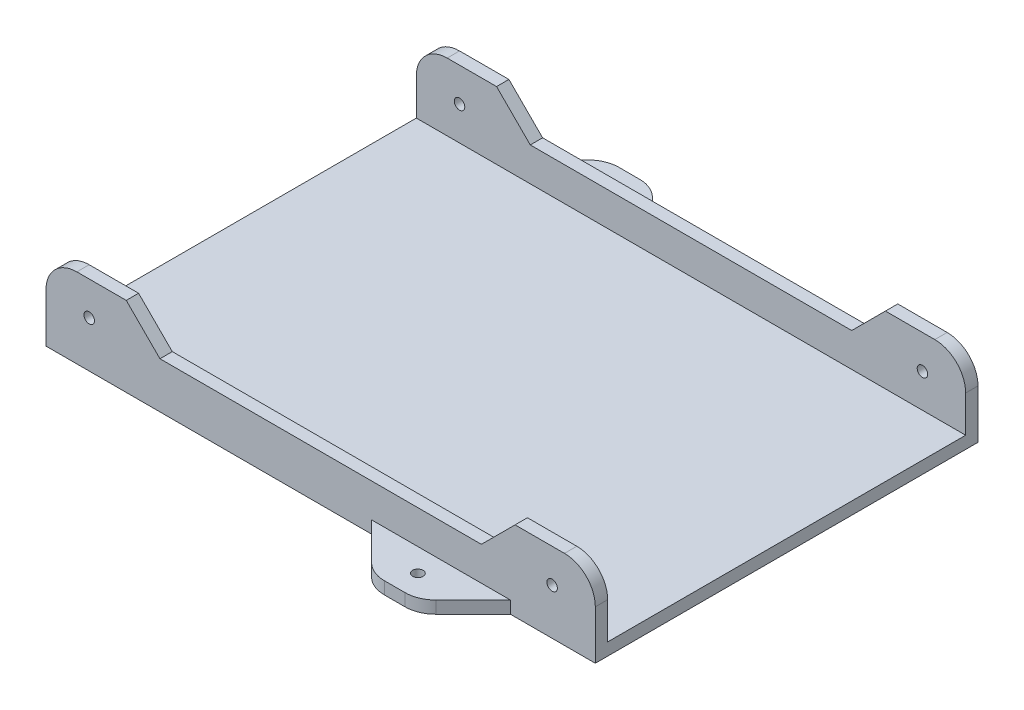
from build123d import *

# Parameters (mm, degrees)
SKETCH1_W               = 178
SKETCH1_H               = 25.844
SKETCH1_R               = 1.7
BOSS_EXTRUDE1_DEPTH     = 4
SKETCH1_3_W             = 178
SKETCH1_3_H             = 4
BOSS_EXTRUDE2_DEPTH     = 116
BOSS_EXTRUDE3_START     = 4
SKETCH2_W               = 178
SKETCH2_H               = 25.844
SKETCH2_R               = 1.7
BOSS_EXTRUDE3_DEPTH     = 4
FILLET1_R               = 10
SKETCH3_R               = 1.7
BOSS_EXTRUDE4_DEPTH     = 4
FILLET2_R               = 10
CUT_EXTRUDE1_DEPTH      = 227.896805478
CUT_EXTRUDE1_DEPTH_BACK = 227.896805478
SKETCH4_R               = 1.7


with BuildPart() as part:
    # Sketch1 → Boss-Extrude1 (new body)
    with BuildSketch(Plane.XY):
        with Locations((89, 8.922)):
            Rectangle(SKETCH1_W, SKETCH1_H)
        with Locations((14, 10.922)):
            Circle(SKETCH1_R, mode=Mode.SUBTRACT)
        with Locations((164, 10.922)):
            Circle(SKETCH1_R, mode=Mode.SUBTRACT)
    extrude(amount=BOSS_EXTRUDE1_DEPTH)

    # Sketch1_3 → Boss-Extrude2 (add)
    with BuildSketch(Plane.XY):
        with Locations((89, -2)):
            Rectangle(SKETCH1_3_W, SKETCH1_3_H)
    extrude(amount=-BOSS_EXTRUDE2_DEPTH)

    # Sketch2 → Boss-Extrude3 (add)
    with BuildSketch(Plane(origin=(0, 0, -116), x_dir=(-1, 0, 0), z_dir=(0, 0, -1)).offset(BOSS_EXTRUDE3_START)):
        with Locations((-89, 8.922)):
            Rectangle(SKETCH2_W, SKETCH2_H)
        with Locations((-14, 10.922)):
            Circle(SKETCH2_R, mode=Mode.SUBTRACT)
        with Locations((-164, 10.922)):
            Circle(SKETCH2_R, mode=Mode.SUBTRACT)
    extrude(amount=-BOSS_EXTRUDE3_DEPTH)

    # Fillet1
    fillet1_edges = [part.edges().sort_by_distance(p)[0] for p in [
        (0, 21.844, -118),
        (0, 21.844, 2),
        (178, 21.844, -118),
        (178, 21.844, 2),
    ]]
    fillet(fillet1_edges, radius=FILLET1_R)

    # Sketch3 → Boss-Extrude4 (add)
    # profile 1 of 2: a face of its own
    with BuildSketch(Plane.XZ.offset(4)):
        Polygon((150.5, 4), (135.5, 19), (120.5, 19), (105.5, 4), align=None)
        with Locations((128, 11.5)):
            Circle(SKETCH3_R, mode=Mode.SUBTRACT)
    # profile 2 of 2: a face of its own
    with BuildSketch(Plane.XZ.offset(4)):
        Polygon((27.5, -120), (42.5, -135), (57.5, -135), (72.5, -120), align=None)
        with Locations((50, -127.5)):
            Circle(SKETCH3_R, mode=Mode.SUBTRACT)
    extrude(amount=-BOSS_EXTRUDE4_DEPTH)

    # Fillet2
    fillet2_edges = [part.edges().sort_by_distance(p)[0] for p in [
        (42.5, -2, -135),
        (57.5, -2, -135),
        (120.5, -2, 19),
        (135.5, -2, 19),
    ]]
    fillet(fillet2_edges, radius=FILLET2_R)

    # Sketch4 → Cut-Extrude1 (cut, two sides: drawn at the far end of the back side and taken through both)
    with BuildSketch(Plane(origin=(0, 0, -120), x_dir=(-1, 0, 0), z_dir=(0, 0, -1)).offset(-CUT_EXTRUDE1_DEPTH_BACK)):
        with Locations((-164, 10.922)):
            Circle(SKETCH4_R)
        Polygon((-152, 21.844), (-141.078, 10.922), (-36.922, 10.922), (-26, 21.844), align=None)
    extrude(amount=CUT_EXTRUDE1_DEPTH + CUT_EXTRUDE1_DEPTH_BACK, mode=Mode.SUBTRACT)


solid = part.part
